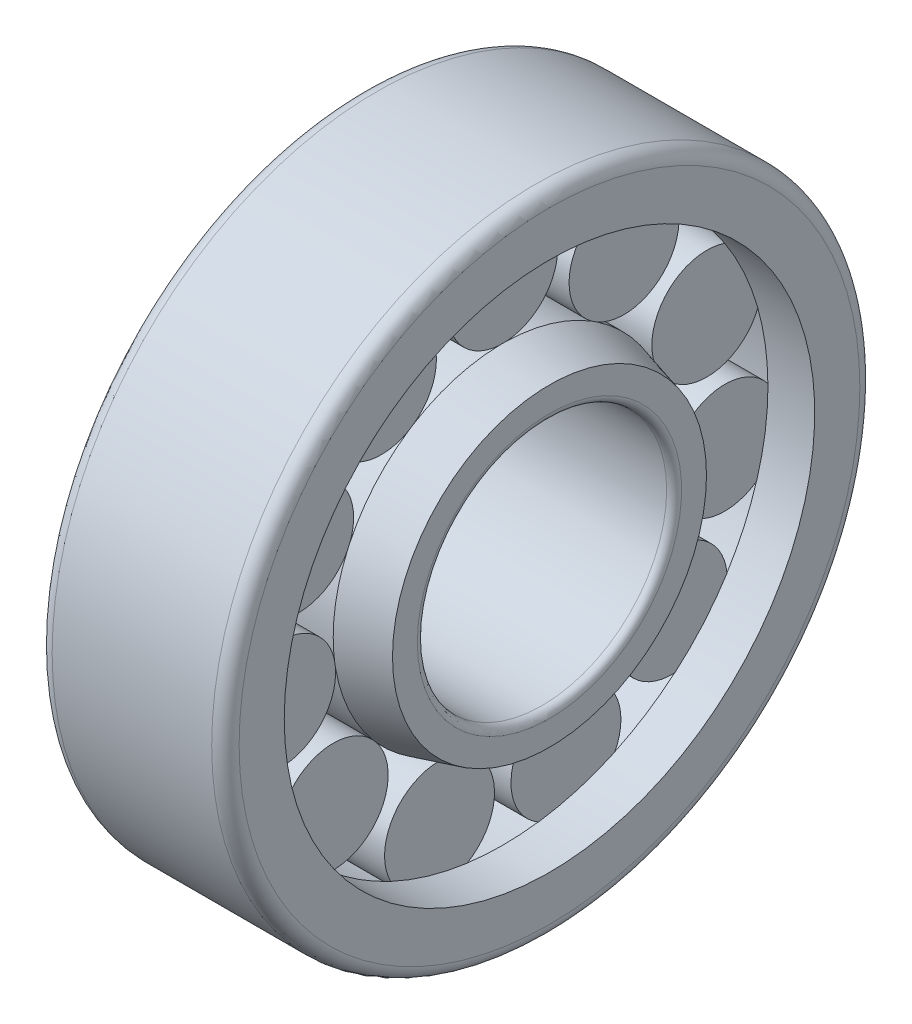
from build123d import *

# Parameters (mm, degrees)
SKETCH2_W               = 7.5
SKETCH2_H               = 4.41
CIRCULAR_PATTERN1_COUNT = 11
FILLET1_R               = 1.1
FILLET2_R               = 0.6


with BuildPart() as part:
    # Sketch1 → Revolve1 (revolve)
    with BuildSketch(Plane.XY):
        Polygon((-7.5, 10), (7.5, 10), (7.5, 12.595190528), (3.75, 13.6), (-3.75, 13.6), (-7.5, 12.595190528), align=None)
    revolve(axis=Axis((-10.137871204, 0, 0), (1, 0, 0)))

    # Sketch2 → Revolve2 (revolve)
    with BuildSketch(Plane.XY):
        with Locations((0, 15.795)):
            Rectangle(SKETCH2_W, SKETCH2_H)
    revolve2 = revolve(axis=Axis((-7.422783257, 18, 0), (1, 0, 0)))

    # Sketch3 → Revolve3 (revolve)
    with BuildSketch(Plane.XY):
        Polygon((-7.5, 26), (7.5, 26), (7.5, 21.28), (3.74, 21.28), (3.74, 22.4), (-3.74, 22.4), (-3.74, 21.28), (-7.5, 21.28), align=None)
    revolve(axis=Axis((-9.082213196, 0, 0), (1, 0, 0)))

    # Circular-Pattern1: Revolve2 ×11 about axis
    circular_pattern1_axis = Axis((0, 0, 0), (1, 0, 0))
    for i in range(1, CIRCULAR_PATTERN1_COUNT):
        add(revolve2.rotate(circular_pattern1_axis, i * 360 / CIRCULAR_PATTERN1_COUNT))

    # Fillet1
    fillet1_edges = [part.edges().sort_by_distance(p)[0] for p in [
        (-7.5, -26, 0),
        (7.5, -26, 0),
    ]]
    fillet(fillet1_edges, radius=FILLET1_R)

    # Fillet2
    fillet2_edges = [part.edges().sort_by_distance(p)[0] for p in [
        (7.5, -10, 0),
        (-7.5, -10, 0),
    ]]
    fillet(fillet2_edges, radius=FILLET2_R)


solid = part.part
